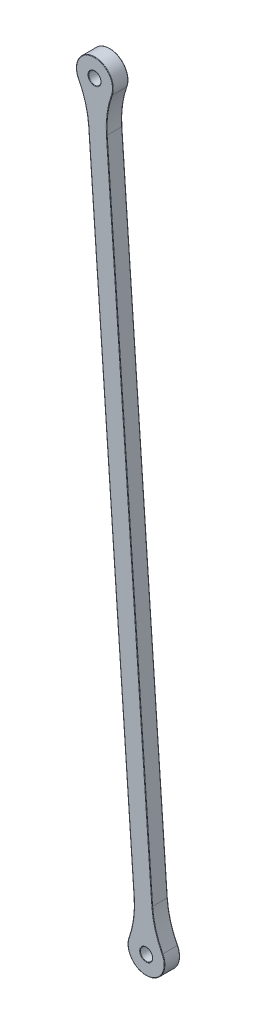
from build123d import *

# Parameters (mm, degrees)
SKETCH1_R           = 2
BOSS_EXTRUDE1_DEPTH = 5
FILLET1_R           = 30
FILLET3_R           = 0.15


with BuildPart() as part:
    # Sketch1 → Boss-Extrude1 (new body)
    with BuildSketch(Plane.XY):
        with BuildLine():
            Line((13.535081633, 282.570881488), (29.663369528, 53.530334851))
            ThreePointArc((29.663369528, 53.530334851), (32.599494793, 54.54292527), (35.64854907, 53.951791664))
            Line((35.64854907, 53.951791664), (19.520261175, 282.992338301))
            ThreePointArc((19.520261175, 282.992338301), (16.58413591, 281.979747882), (13.535081633, 282.570881488))
        make_face()
        with BuildLine():
            Line((13.170089326, 287.754199018), (13.535081633, 282.570881488))
            ThreePointArc((13.535081633, 282.570881488), (16.58413591, 281.979747882), (19.520261175, 282.992338301))
            Line((19.520261175, 282.992338301), (19.155268869, 288.175655831))
            ThreePointArc((19.155268869, 288.175655831), (16.373407504, 284.972337653), (13.170089326, 287.754199018))
        make_face()
        with BuildLine():
            ThreePointArc((22.162679097, 287.964927424), (12.981923274, 293.052440804), (13.535081633, 282.570881488))
            Line((13.535081633, 282.570881488), (13.170089326, 287.754199018))
            ThreePointArc((13.170089326, 287.754199018), (15.951950691, 290.957517195), (19.155268869, 288.175655831))
            Line((19.155268869, 288.175655831), (19.520261175, 282.992338301))
            ThreePointArc((19.520261175, 282.992338301), (21.461051134, 285.149389506), (22.162679097, 287.964927424))
        make_face()
        with BuildLine():
            ThreePointArc((19.155268869, 288.175655831), (15.951950691, 290.957517195), (13.170089326, 287.754199018))
            ThreePointArc((13.170089326, 287.754199018), (16.373407504, 284.972337653), (19.155268869, 288.175655831))
        make_face()
        with Locations((16.162679097, 287.964927424)):
            Circle(SKETCH1_R, mode=Mode.SUBTRACT)
        with BuildLine():
            ThreePointArc((30.028361834, 48.347017321), (33.231680012, 45.565155956), (36.013541377, 48.768474134))
            ThreePointArc((36.013541377, 48.768474134), (32.810223199, 51.550335499), (30.028361834, 48.347017321))
        make_face()
        with Locations((33.020951605, 48.557745727)):
            Circle(SKETCH1_R, mode=Mode.SUBTRACT)
        with BuildLine():
            ThreePointArc((36.013541377, 48.768474134), (33.231680012, 45.565155956), (30.028361834, 48.347017321))
            Line((30.028361834, 48.347017321), (29.663369528, 53.530334851))
            ThreePointArc((29.663369528, 53.530334851), (30.205413687, 43.259373691), (39.020951605, 48.557745727))
            ThreePointArc((39.020951605, 48.557745727), (38.108464986, 51.73850155), (35.64854907, 53.951791664))
            Line((35.64854907, 53.951791664), (36.013541377, 48.768474134))
        make_face()
        with BuildLine():
            Line((29.663369528, 53.530334851), (30.028361834, 48.347017321))
            ThreePointArc((30.028361834, 48.347017321), (32.810223199, 51.550335499), (36.013541377, 48.768474134))
            Line((36.013541377, 48.768474134), (35.64854907, 53.951791664))
            ThreePointArc((35.64854907, 53.951791664), (32.599494793, 54.54292527), (29.663369528, 53.530334851))
        make_face()
    extrude(amount=-BOSS_EXTRUDE1_DEPTH)

    # Fillet1
    fillet1_edges = [part.edges().sort_by_distance(p)[0] for p in [
        (29.663369528, 53.530334851, -2.5),
        (13.535081633, 282.570881488, -2.5),
        (19.520261175, 282.992338301, -2.5),
        (35.64854907, 53.951791664, -2.5),
    ]]
    fillet(fillet1_edges, radius=FILLET1_R)

    # Fillet3
    fillet3_edges = [part.edges().sort_by_distance(p)[0] for p in [
        (27.584405123, 168.472064982, 0),
        (27.584405123, 168.472064982, -5),
        (15.741222285, 293.950106967, 0),
        (15.741222285, 293.950106967, -5),
        (21.59922558, 168.050608169, 0),
        (14.162679097, 287.964927424, -5),
        (21.59922558, 168.050608169, -5),
        (32.0033823, 42.644662546, 0),
        (32.0033823, 42.644662546, -5),
        (20.36582871, 279.976666604, 0),
        (20.36582871, 279.976666604, -5),
        (31.020951605, 48.557745727, -5),
        (13.120470236, 279.466472103, 0),
        (13.120470236, 279.466472103, -5),
        (28.817801992, 56.546006547, 0),
        (28.817801992, 56.546006547, -5),
        (36.063160467, 57.056201048, 0),
        (36.063160467, 57.056201048, -5),
        (31.020951605, 48.557745727, 0),
        (14.162679097, 287.964927424, 0),
    ]]
    fillet(fillet3_edges, radius=FILLET3_R)


solid = part.part
